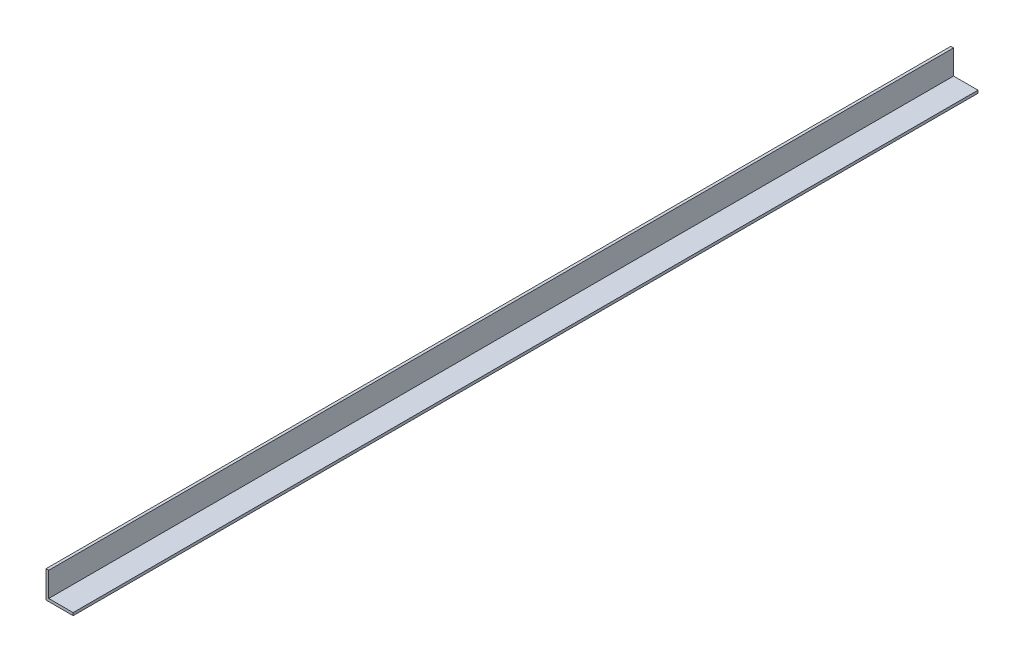
from build123d import *

# Parameters (mm, degrees)
EXTRUDE_1_DEPTH = 1000


with BuildPart() as part:
    # Эскиз1 → Бобышка-Вытянуть1 (new body)
    with BuildSketch(Plane.XY):
        Polygon((0, 30), (0, 0), (30, 0), (30, 3), (3, 3), (3, 30), align=None)
    extrude(amount=EXTRUDE_1_DEPTH)


solid = part.part
